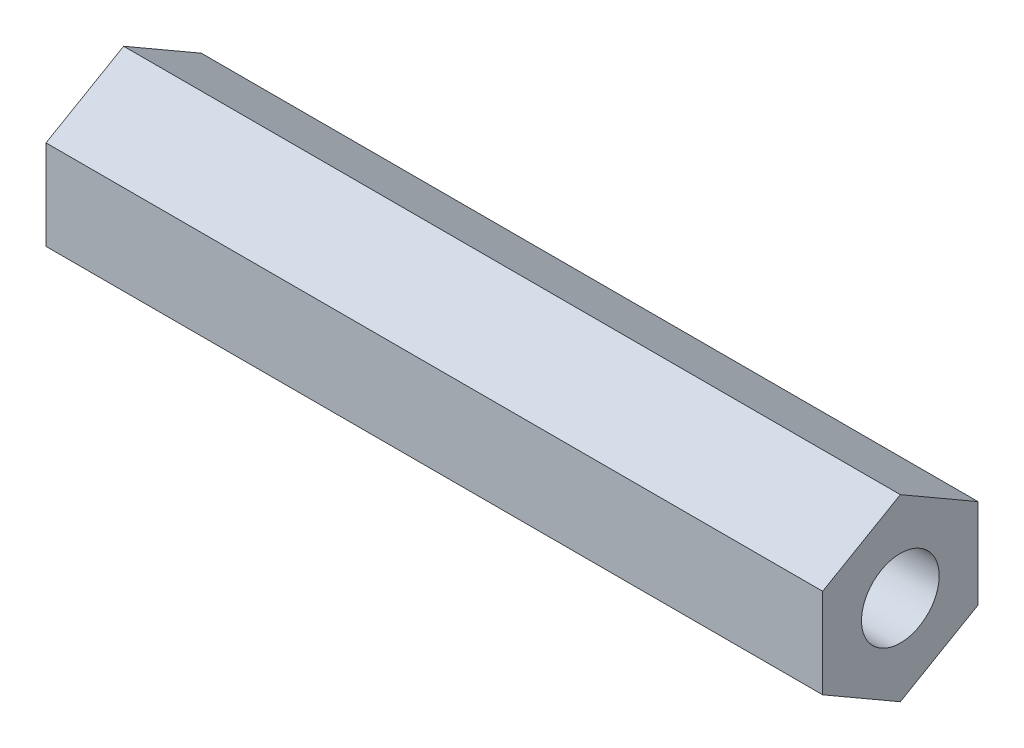
from build123d import *

# Parameters (mm, degrees)
SKETCH1_R           = 1.5
BOSS_EXTRUDE1_DEPTH = 30


with BuildPart() as part:
    # Sketch1 → Boss-Extrude1 (new body)
    with BuildSketch(Plane(origin=(0, 0, 0), x_dir=(0, 0, -1), z_dir=(1, 0, 0))):
        Polygon((-42.728336364, 8.277130653), (-45.728336364, 6.545079846), (-45.728336364, 3.08097823), (-42.728336364, 1.348927423), (-39.728336364, 3.08097823), (-39.728336364, 6.545079846), align=None)
        with Locations((-42.728336364, 4.813029038)):
            Circle(SKETCH1_R, mode=Mode.SUBTRACT)
    extrude(amount=BOSS_EXTRUDE1_DEPTH)


solid = part.part
